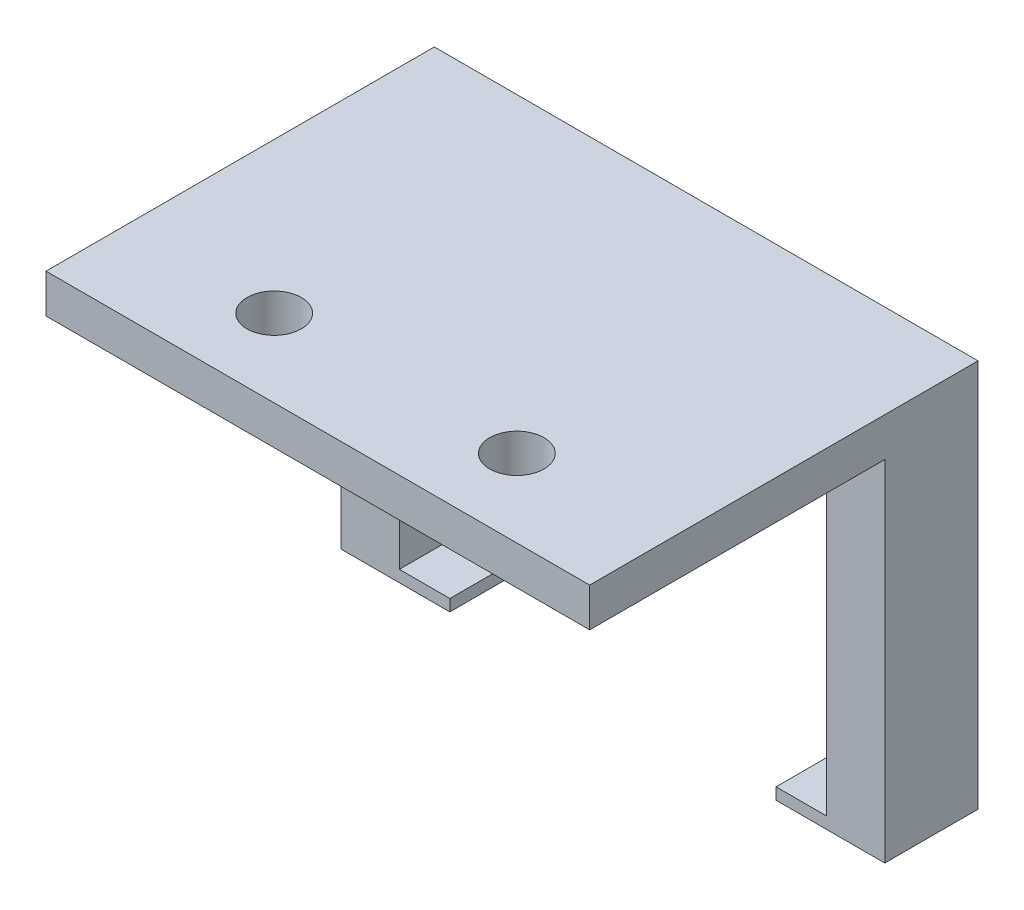
from build123d import *

# Parameters (mm, degrees)
SKETCH3_W           = 35.56
SKETCH3_H           = 25.4
SKETCH3_R           = 1.778
BOSS_EXTRUDE3_DEPTH = 2.54
SKETCH4_W           = 3.81
SKETCH4_H           = 11.176
BOSS_EXTRUDE4_DEPTH = 22.86
SKETCH5_W           = 11.176
SKETCH5_H           = 0.762
BOSS_EXTRUDE5_DEPTH = 3.302
SKETCH6_W           = 11.176
SKETCH6_H           = 0.762
BOSS_EXTRUDE6_DEPTH = 3.302
SKETCH7_W           = 35.56
SKETCH7_H           = 22.86
CUT_EXTRUDE1_DEPTH  = 5.08


with BuildPart() as part:
    # Sketch3 → Boss-Extrude3 (new body)
    with BuildSketch(Plane(origin=(0, 0, 0), x_dir=(1, 0, 0), z_dir=(0, 1, 0))):
        with Locations((6.262748092, -0.232671756)):
            Rectangle(SKETCH3_W, SKETCH3_H)
        with Locations((-1.674751908, -7.852671756)):
            Circle(SKETCH3_R, mode=Mode.SUBTRACT)
        with Locations((14.200248092, -7.852671756)):
            Circle(SKETCH3_R, mode=Mode.SUBTRACT)
    extrude(amount=BOSS_EXTRUDE3_DEPTH)

    # Sketch4 → Boss-Extrude4 (add)
    with BuildSketch(Plane.XZ):
        with Locations((-9.612251908, -6.879328244)):
            Rectangle(SKETCH4_W, SKETCH4_H)
        with Locations((22.137748092, -6.879328244)):
            Rectangle(SKETCH4_W, SKETCH4_H)
    extrude(amount=BOSS_EXTRUDE4_DEPTH)

    # Sketch5 → Boss-Extrude5 (add)
    with BuildSketch(Plane(origin=(-7.707251908, 0, 0), x_dir=(0, 0, -1), z_dir=(1, 0, 0))):
        with Locations((6.879328244, -22.479)):
            Rectangle(SKETCH5_W, SKETCH5_H)
    extrude(amount=BOSS_EXTRUDE5_DEPTH)

    # Sketch6 → Boss-Extrude6 (add)
    with BuildSketch(Plane.ZY.offset(-20.232748092)):
        with Locations((-6.879328244, -22.479)):
            Rectangle(SKETCH6_W, SKETCH6_H)
    extrude(amount=BOSS_EXTRUDE6_DEPTH)

    # Sketch7 → Cut-Extrude1 (cut)
    with BuildSketch(Plane.XY.offset(-1.291328244)):
        with Locations((6.262748092, -11.43)):
            Rectangle(SKETCH7_W, SKETCH7_H)
    extrude(amount=-CUT_EXTRUDE1_DEPTH, mode=Mode.SUBTRACT)


solid = part.part
